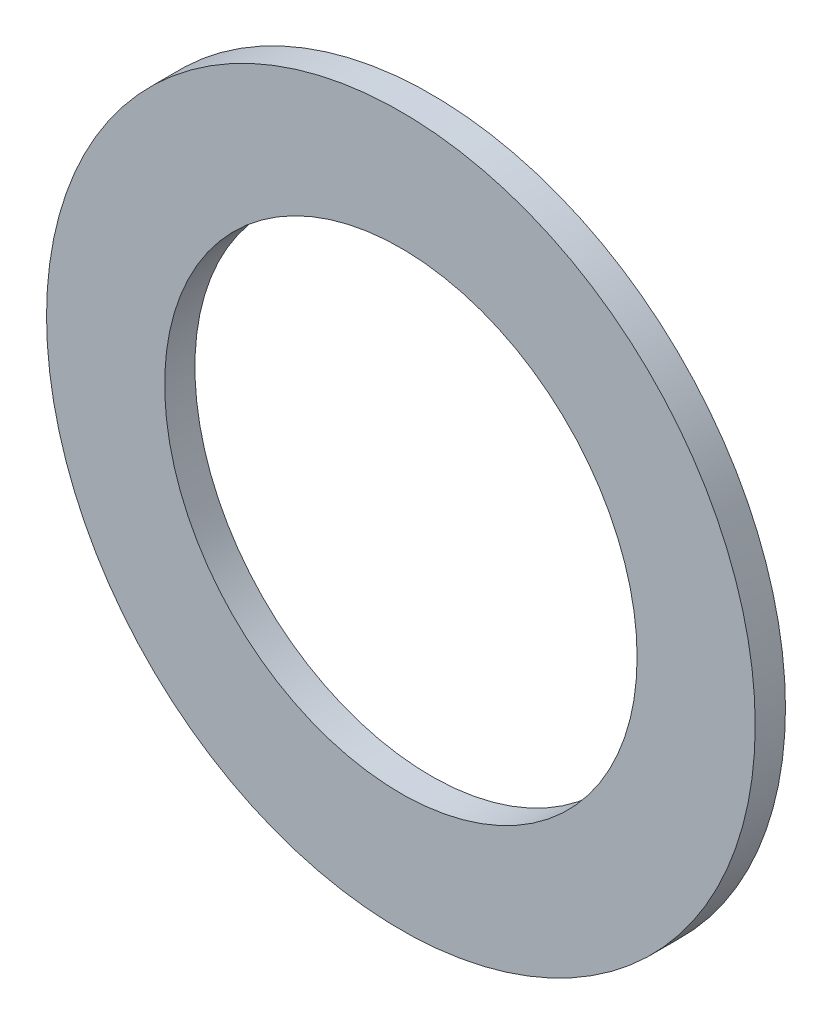
from build123d import *

# Parameters (mm, degrees)
SKETCH1_R           = 9.525
SKETCH1_R_2         = 6.35
BOSS_EXTRUDE1_DEPTH = 0.8128


with BuildPart() as part:
    # Sketch1 → Boss-Extrude1 (new body)
    with BuildSketch(Plane.XY):
        Circle(SKETCH1_R)
        Circle(SKETCH1_R_2, mode=Mode.SUBTRACT)
    extrude(amount=BOSS_EXTRUDE1_DEPTH)


solid = part.part
